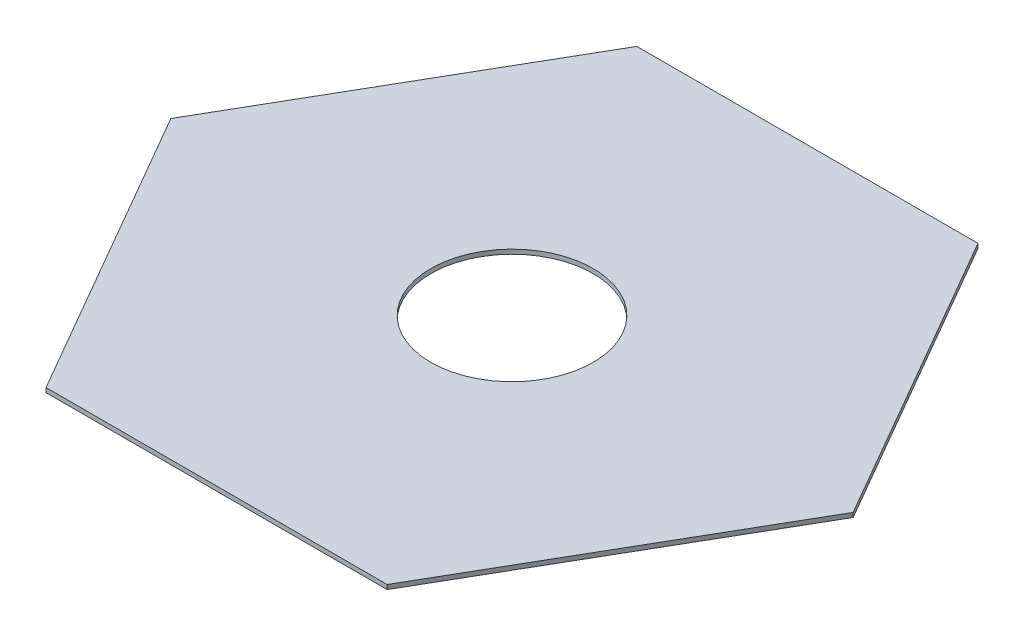
from build123d import *

# Parameters (mm, degrees)
CROQUIS1_R              = 55
SALIENTE_EXTRUIR1_DEPTH = 3


with BuildPart() as part:
    # Croquis1 → Saliente-Extruir1 (new body)
    with BuildSketch(Plane(origin=(0, 0, 0), x_dir=(1, 0, 0), z_dir=(0, 1, 0))):
        Polygon((115.470053838, -200), (230.940107676, 0), (115.470053838, 200), (-115.470053838, 200), (-230.940107676, 0), (-115.470053838, -200), align=None)
        Circle(CROQUIS1_R, mode=Mode.SUBTRACT)
    extrude(amount=SALIENTE_EXTRUIR1_DEPTH)


solid = part.part
